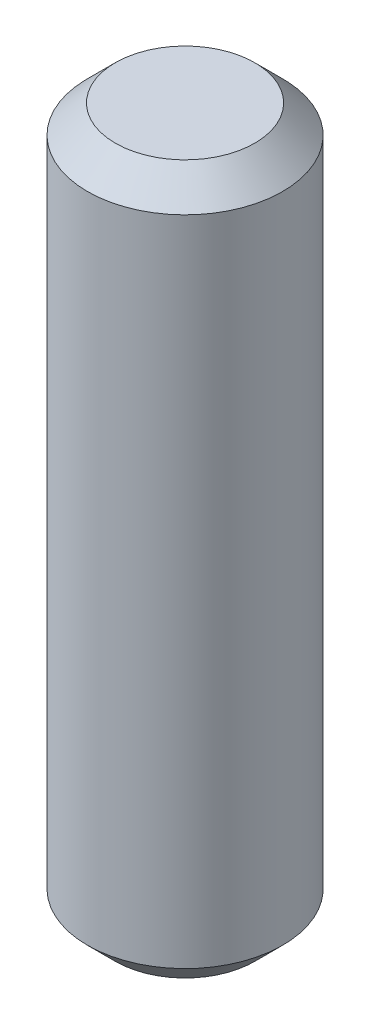
from build123d import *

# Parameters (mm, degrees)
SKETCH1_R           = 1.75
BOSS_EXTRUDE1_DEPTH = 12.7
CHAMFER1_SIZE       = 0.5


with BuildPart() as part:
    # Sketch1 → Boss-Extrude1 (new body)
    with BuildSketch(Plane(origin=(0, 0, 0), x_dir=(1, 0, 0), z_dir=(0, 1, 0))):
        Circle(SKETCH1_R)
    extrude(amount=BOSS_EXTRUDE1_DEPTH)

    # Chamfer1
    chamfer1_edges = [part.edges().sort_by_distance(p)[0] for p in [
        (-1.75, 0, 0),
        (-1.75, 12.7, 0),
    ]]
    chamfer(chamfer1_edges, length=CHAMFER1_SIZE)


solid = part.part
